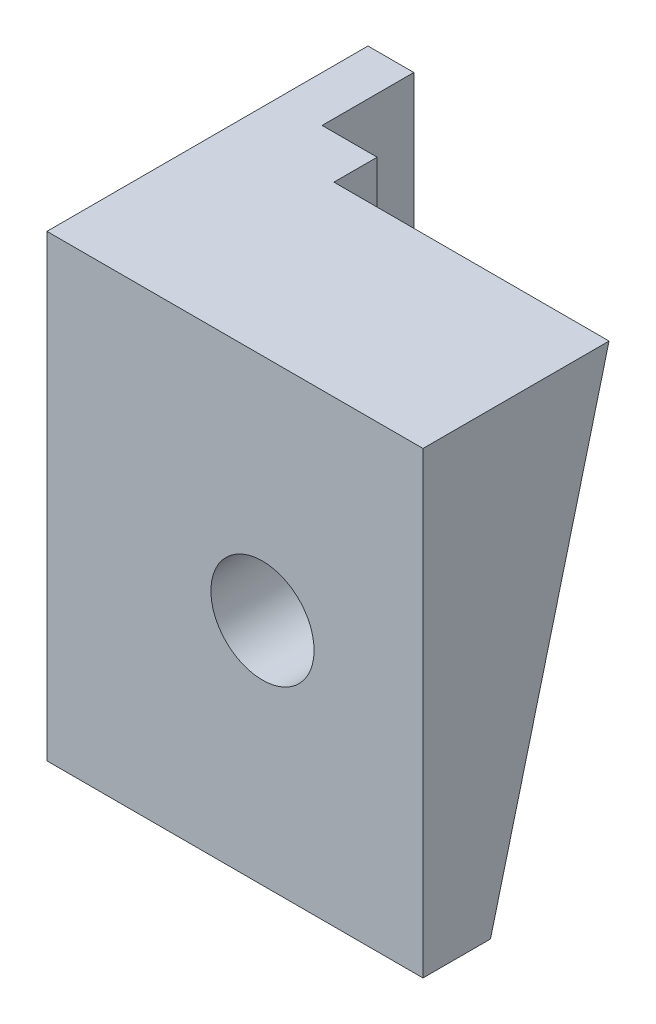
from build123d import *

# Parameters (mm, degrees)
SKETCH2_W           = 2.2
SKETCH2_H           = 10
BOSS_EXTRUDE1_DEPTH = 5
SKETCH2_3_W         = 1
SKETCH2_3_H         = 10
BOSS_EXTRUDE2_DEPTH = 2
BOSS_EXTRUDE3_DEPTH = 6
SKETCH4_R           = 1.125
CUT_EXTRUDE1_DEPTH  = 6


with BuildPart() as part:
    # Sketch2 → Boss-Extrude1 (new body)
    with BuildSketch(Plane.XY):
        with Locations((1.1, 5)):
            Rectangle(SKETCH2_W, SKETCH2_H)
    extrude(amount=BOSS_EXTRUDE1_DEPTH)

    # Sketch2_3 → Boss-Extrude2 (add)
    with BuildSketch(Plane.XY):
        with Locations((0.5, 5)):
            Rectangle(SKETCH2_3_W, SKETCH2_3_H)
    extrude(amount=-BOSS_EXTRUDE2_DEPTH)

    # Sketch3 → Boss-Extrude3 (add)
    with BuildSketch(Plane(origin=(2.2, 0, 0), x_dir=(0, 0, -1), z_dir=(1, 0, 0))):
        Polygon((-5, 0), (-3.52903009, 0), (-0.942854246, 10), (-5, 10), align=None)
    extrude(amount=BOSS_EXTRUDE3_DEPTH)

    # Sketch4 → Cut-Extrude1 (cut)
    with BuildSketch(Plane.XY.offset(5)):
        with Locations((4.7, 5)):
            Circle(SKETCH4_R)
    extrude(amount=-CUT_EXTRUDE1_DEPTH, mode=Mode.SUBTRACT)


solid = part.part
